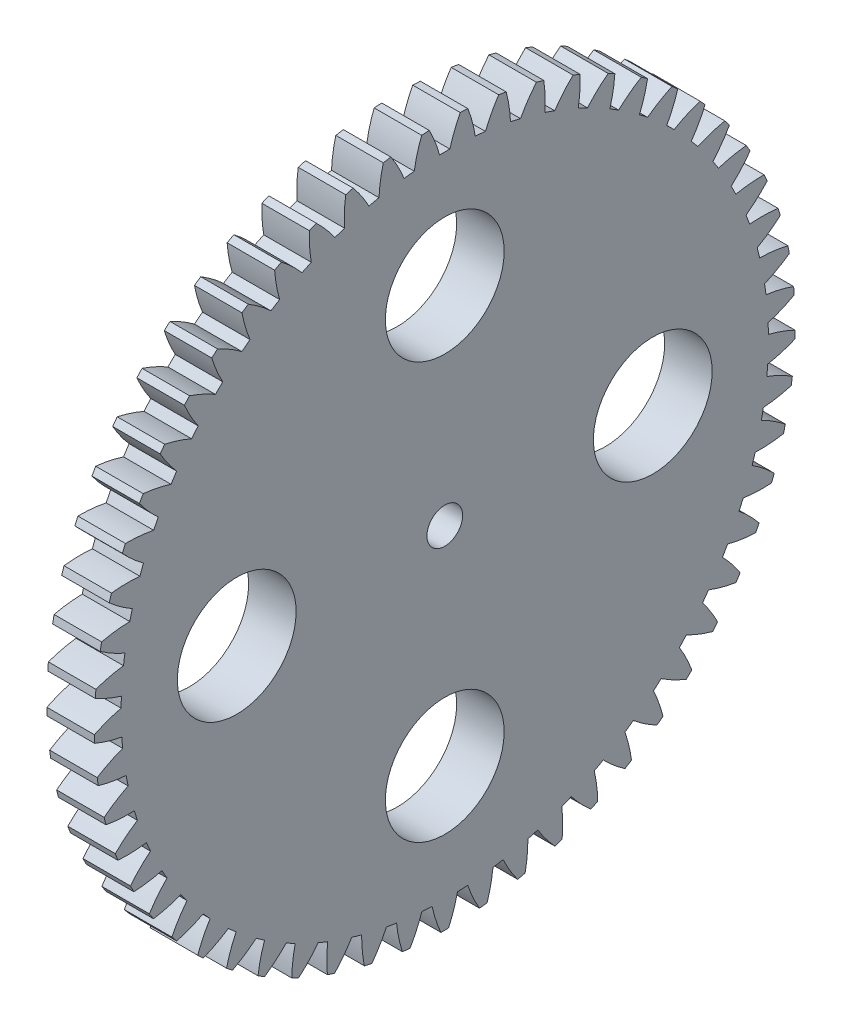
from build123d import *

# Parameters (mm, degrees)
BASPROSKE_W        = 4
BASPROSKE_H        = 29.5
TOOTHCUT_DEPTH     = 42.910619179
TEETHCUTS_COUNT    = 57
TEETHCUTS_ANGLE    = 353.684210526
BORSKE_R           = 1.5
BORE_DEPTH         = 50.0000508
SKETCH1_R          = 5
CUT_EXTRUDE1_DEPTH = 10


with BuildPart() as part:
    # BasProSke → Base-Revolve (revolve)
    with BuildSketch(Plane(origin=(0, 0, 0), x_dir=(1, 0, 0), z_dir=(0, 1, 0)), mode=Mode.PRIVATE) as base_revolve_sk:
        with Locations((2, 14.75)):
            Rectangle(BASPROSKE_W, BASPROSKE_H)
    revolve(base_revolve_sk.sketch.rotate(Axis((-10, 0, 0), (1, 0, 0)), 180), axis=Axis((-10, 0, 0), (1, 0, 0)))

    # TooCutSke → ToothCut (cut, through all)
    with BuildSketch(Plane(origin=(0, 0, 0), x_dir=(0, 0, -1), z_dir=(1, 0, 0))):
        with BuildLine():
            ThreePointArc((0.432142545, 27.245573105), (0, 27.249), (-0.432142545, 27.245573105))
            ThreePointArc((-0.432142545, 27.245573105), (-0.814773323, 28.394321615), (-1.317082666, 29.496008856))
            ThreePointArc((-1.317082666, 29.496008856), (0, 29.5254), (1.317082666, 29.496008856))
            ThreePointArc((1.317082666, 29.496008856), (0.814773323, 28.394321615), (0.432142545, 27.245573105))
        make_face()
    toothcut = extrude(amount=TOOTHCUT_DEPTH, mode=Mode.SUBTRACT)

    # TeethCuts: ToothCut ×57 about axis
    teethcuts_axis = Axis((-10, 0, 0), (1, 0, 0))
    for i in range(1, TEETHCUTS_COUNT):
        add(toothcut.rotate(teethcuts_axis, i * TEETHCUTS_ANGLE / (TEETHCUTS_COUNT - 1)), mode=Mode.SUBTRACT)

    # BorSke → Bore (cut, symmetric)
    with BuildSketch(Plane(origin=(0, 0, 0), x_dir=(0, 0, -1), z_dir=(1, 0, 0))):
        with Locations(Location((0, 0, 0), (0, 0, 180))):
            Circle(BORSKE_R)
    extrude(amount=BORE_DEPTH, both=True, mode=Mode.SUBTRACT)

    # Sketch1 → Cut-Extrude1 (cut)
    with BuildSketch(Plane(origin=(4, 0, 0), x_dir=(0, 0, -1), z_dir=(1, 0, 0))):
        with Locations((0, -17.513416598)):
            Circle(SKETCH1_R)
        with Locations((-17.513416598, 0)):
            Circle(SKETCH1_R)
        with Locations((0, 17.513416598)):
            Circle(SKETCH1_R)
        with Locations((17.513416598, 0)):
            Circle(SKETCH1_R)
    extrude(amount=-CUT_EXTRUDE1_DEPTH, mode=Mode.SUBTRACT)


solid = part.part
